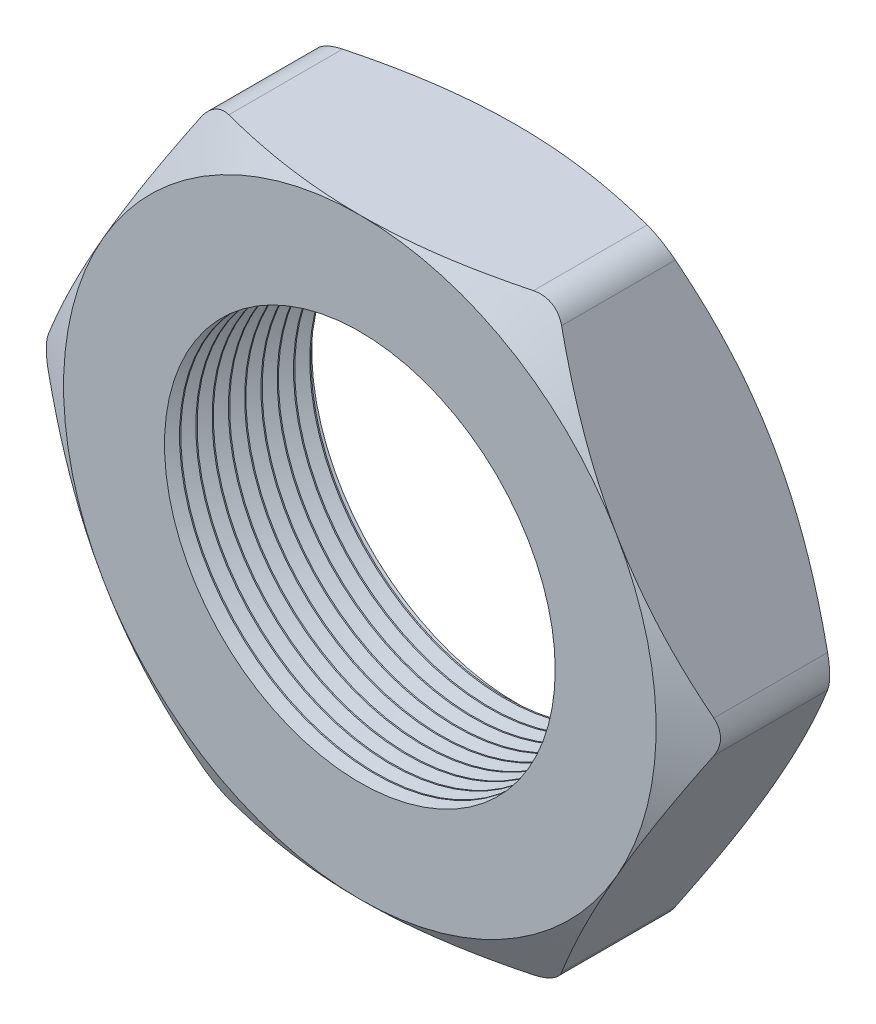
from build123d import *

# Parameters (mm, degrees)
SKETCH1_R          = 7.62
EXTRUDE1_DEPTH     = 6.096
SKETCH2_OUTSIDE_W  = 60.438
SKETCH2_OUTSIDE_H  = 56.862
SKETCH2_OUTSIDE_R  = 11.557
CUT_EXTRUDE1_DEPTH = 7.096
CUT_EXTRUDE1_DRAFT = -60
SKETCH3_OUTSIDE_W  = 60.438
SKETCH3_OUTSIDE_H  = 56.862
SKETCH3_OUTSIDE_R  = 11.557
CUT_EXTRUDE2_DEPTH = 7.096
CUT_EXTRUDE2_DRAFT = -60
FILLET1_R          = 1.27
LPATTERN1_COUNT    = 10
LPATTERN1_PITCH    = 0.635


with BuildPart() as part:
    # Sketch1 → Extrude1 (new body)
    with BuildSketch(Plane.XY):
        Polygon((-13.344874122, 0), (-6.672437061, -11.557), (6.672437061, -11.557), (13.344874122, 0), (6.672437061, 11.557), (-6.672437061, 11.557), align=None)
        Circle(SKETCH1_R, mode=Mode.SUBTRACT)
    extrude(amount=EXTRUDE1_DEPTH)


with BuildPart() as cut_extrude1_tool:
    # Sketch2 outside → Cut-Extrude1 (with draft: the straight prism first)
    with BuildSketch(Plane.XY.offset(6.096)):
        Rectangle(SKETCH2_OUTSIDE_W, SKETCH2_OUTSIDE_H)
        Circle(SKETCH2_OUTSIDE_R, mode=Mode.SUBTRACT)
    extrude(amount=-CUT_EXTRUDE1_DEPTH)
    # Cut-Extrude1: the draft: its side faces are tilted about the plane it starts from
    cut_extrude1_sides = [cut_extrude1_tool.faces().sort_by_distance(p)[0] for p in [
        (0, -28.431, 2.548),
        (30.219, 0, 2.548),
        (0, 28.431, 2.548),
        (-30.219, 0, 2.548),
        (-11.557, 0, 2.548),
    ]]
    draft(cut_extrude1_sides, Plane.XY.offset(6.096), CUT_EXTRUDE1_DRAFT)


with BuildPart() as part_1:
    add(part.part)

    # Cut-Extrude1: cut by cut_extrude1_tool
    add(cut_extrude1_tool.part, mode=Mode.SUBTRACT)


with BuildPart() as cut_extrude2_tool:
    # Sketch3 outside → Cut-Extrude2 (with draft: the straight prism first)
    with BuildSketch(Plane(origin=(0, 0, 0), x_dir=(-1, 0, 0), z_dir=(0, 0, -1))):
        Rectangle(SKETCH3_OUTSIDE_W, SKETCH3_OUTSIDE_H)
        Circle(SKETCH3_OUTSIDE_R, mode=Mode.SUBTRACT)
    extrude(amount=-CUT_EXTRUDE2_DEPTH)
    # Cut-Extrude2: the draft: its side faces are tilted about the plane it starts from
    cut_extrude2_sides = [cut_extrude2_tool.faces().sort_by_distance(p)[0] for p in [
        (0, -28.431, 3.548),
        (-30.219, 0, 3.548),
        (0, 28.431, 3.548),
        (30.219, 0, 3.548),
        (11.557, 0, 3.548),
    ]]
    draft(cut_extrude2_sides, Plane(origin=(0, 0, 0), x_dir=(-1, 0, 0), z_dir=(0, 0, -1)), CUT_EXTRUDE2_DRAFT)


with BuildPart() as part_2:
    add(part_1.part)

    # Cut-Extrude2: cut by cut_extrude2_tool
    add(cut_extrude2_tool.part, mode=Mode.SUBTRACT)

    # Fillet1
    fillet1_edges = [part_2.edges().sort_by_distance(p)[0] for p in [
        (13.344874122, 0, 3.048),
        (6.672437061, -11.557, 3.048),
        (-6.672437061, -11.557, 3.048),
        (-13.344874122, 0, 3.048),
        (-6.672437061, 11.557, 3.048),
        (6.672437061, 11.557, 3.048),
    ]]
    fillet(fillet1_edges, radius=FILLET1_R)

    # Sketch4 → Cut-Revolve1 (revolve, cut)
    with BuildSketch(Plane(origin=(0, 0, 0), x_dir=(1, 0, 0), z_dir=(0, 1, 0)), mode=Mode.PRIVATE) as cut_revolve1_sk:
        Polygon((-7.62, -6.096), (-7.62, -5.509412127), (-8.128, -5.802706063), align=None)
    cut_revolve1 = revolve(cut_revolve1_sk.sketch.rotate(Axis((0, 0, 0), (0, 0, 1)), 180), axis=Axis((0, 0, 0), (0, 0, 1)), mode=Mode.SUBTRACT)  # turned: the seam where the file's is

    # LPattern1: Cut-Revolve1 ×10
    with Locations(*[(0, 0, -i * LPATTERN1_PITCH) for i in range(1, LPATTERN1_COUNT)]):
        add(cut_revolve1, mode=Mode.SUBTRACT)


solid = part_2.part
